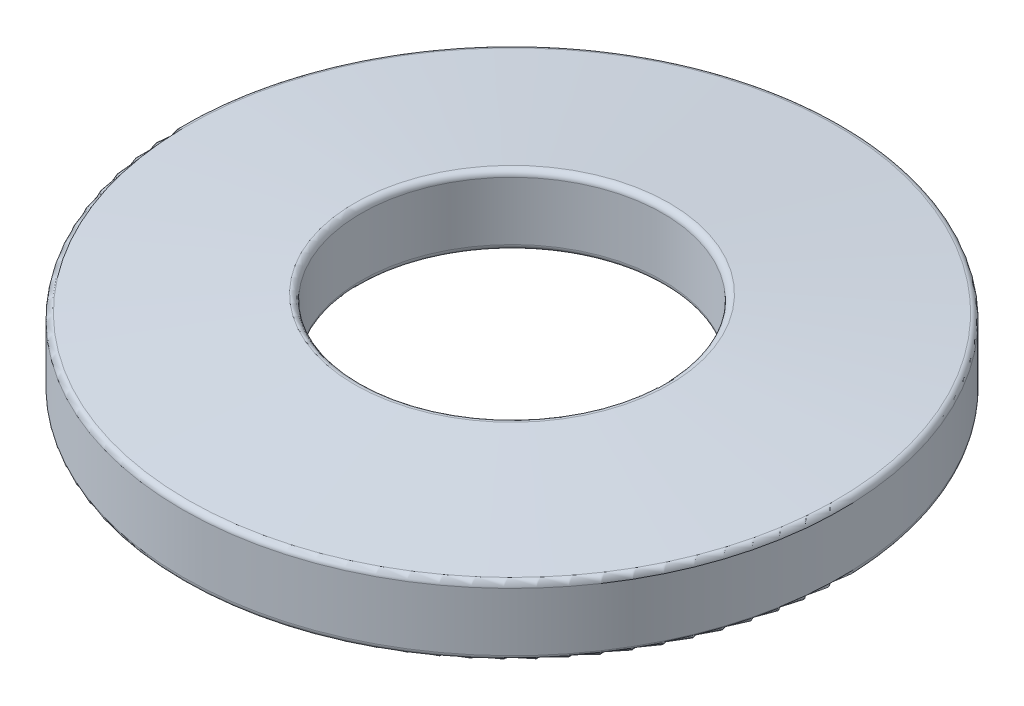
from build123d import *

# Parameters (mm, degrees)
FILLET1_R = 0.254


with BuildPart() as part:
    # Sketch2 → Revolve1 (revolve)
    with BuildSketch(Plane(origin=(0, 0, 0), x_dir=(0, 0, -1), z_dir=(1, 0, 0))):
        Polygon((6.5786, 3.81), (6.5786, 0.762), (14.3637, 0), (14.3637, 3.048), align=None)
    revolve(axis=Axis((0, 0, 0), (0, 1, 0)))

    # Fillet1
    fillet1_edges = [part.edges().sort_by_distance(p)[0] for p in [
        (0, 3.048, 14.3637),
        (0, 0, 14.3637),
        (0, 0.762, 6.5786),
        (0, 3.81, 6.5786),
    ]]
    fillet(fillet1_edges, radius=FILLET1_R)


solid = part.part
